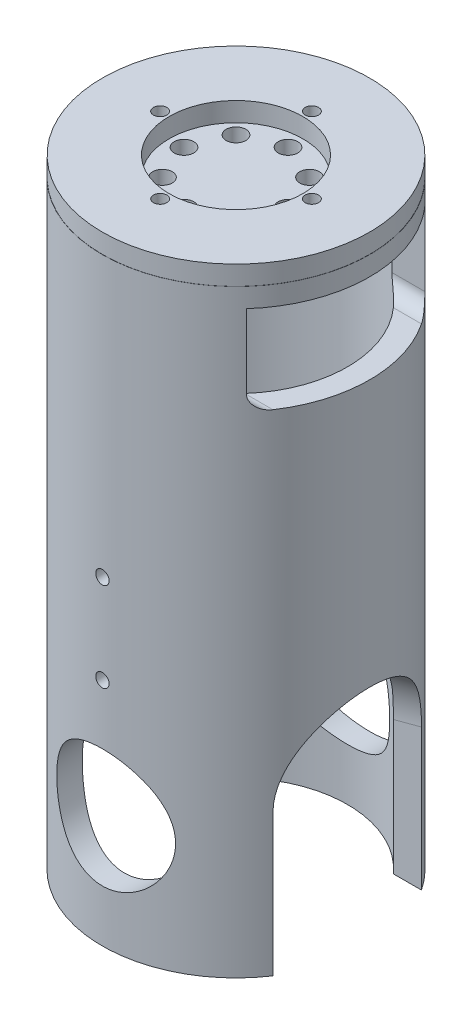
from build123d import *

# Parameters (mm, degrees)
SKETCH1_R                     = 45
BOSS_EXTRUDE2_DEPTH           = 6.5
SKETCH4_R                     = 44.947358216
SKETCH4_R_2                   = 22.5
BOSS_EXTRUDE4_DEPTH           = 6.5
M6_CLEARANCE_HOLE1_D          = 6.6
M6_CLEARANCE_HOLE1_DEPTH      = 10
M6_CLEARANCE_HOLE1_TIP        = 1.982840043
M4_CLEARANCE_HOLE1_D          = 4.5
M4_CLEARANCE_HOLE1_DEPTH      = 20
M4_CLEARANCE_HOLE1_TIP        = 1.351936393
SKETCH18_R                    = 45
SKETCH18_R_2                  = 37.5
BOSS_EXTRUDE7_DEPTH           = 195
SKETCH19_R                    = 20
CUT_EXTRUDE1_DEPTH            = 51
CUT_EXTRUDE1_DEPTH_BACK       = 46
SKETCH21_R                    = 25
CUT_EXTRUDE3_DEPTH            = 65
SKETCH22_R                    = 25
CUT_EXTRUDE4_DEPTH            = 65
CUT_EXTRUDE5_DEPTH            = 47
CUT_EXTRUDE5_DEPTH_BACK       = 47
M4_CLEARANCE_HOLE2_AT_2_COUNT = 2
M4_CLEARANCE_HOLE2_AT_2_PITCH = 30


with BuildPart() as part:
    # Sketch1 → Boss-Extrude2 (new body)
    with BuildSketch(Plane(origin=(0, 0, 0), x_dir=(1, 0, 0), z_dir=(0, 1, 0))):
        Circle(SKETCH1_R)
    extrude(amount=BOSS_EXTRUDE2_DEPTH)

    # Sketch4 → Boss-Extrude4 (add)
    with BuildSketch(Plane(origin=(0, 6.5, 0), x_dir=(1, 0, 0), z_dir=(0, 1, 0))):
        Circle(SKETCH4_R)
        Circle(SKETCH4_R_2, mode=Mode.SUBTRACT)
    extrude(amount=BOSS_EXTRUDE4_DEPTH)

    # M6 Clearance Hole1
    with Locations(Plane(origin=(0, 6.5, 0), x_dir=(1, 0, 0), z_dir=(0, 1, 0))):
        with Locations((0, -17.5), (12.374368671, -12.374368671), (17.5, 0), (12.374368671, 12.374368671), (0, 17.5), (-12.374368671, 12.374368671), (-17.5, 0), (-12.374368671, -12.374368671)):
            Hole(M6_CLEARANCE_HOLE1_D / 2, depth=M6_CLEARANCE_HOLE1_DEPTH)
            with Locations((0, 0, -(M6_CLEARANCE_HOLE1_DEPTH + M6_CLEARANCE_HOLE1_TIP / 2))):  # 118° drill point
                Cone(0, M6_CLEARANCE_HOLE1_D / 2, M6_CLEARANCE_HOLE1_TIP, mode=Mode.SUBTRACT)

    # M4 Clearance Hole1
    with Locations(Plane(origin=(0, 13, 0), x_dir=(1, 0, 0), z_dir=(0, 1, 0))):
        with Locations((0, -25.525), (25.525, 0), (0, 25.525), (-25.525, 0)):
            Hole(M4_CLEARANCE_HOLE1_D / 2, depth=M4_CLEARANCE_HOLE1_DEPTH)
            with Locations((0, 0, -(M4_CLEARANCE_HOLE1_DEPTH + M4_CLEARANCE_HOLE1_TIP / 2))):  # 118° drill point
                Cone(0, M4_CLEARANCE_HOLE1_D / 2, M4_CLEARANCE_HOLE1_TIP, mode=Mode.SUBTRACT)

    # Sketch18 → Boss-Extrude7 (add)
    with BuildSketch(Plane(origin=(0, 0, 0), x_dir=(-1, 0, 0), z_dir=(0, -1, 0))):
        Circle(SKETCH18_R)
        Circle(SKETCH18_R_2, mode=Mode.SUBTRACT)
    extrude(amount=BOSS_EXTRUDE7_DEPTH)

    # Sketch19 → Cut-Extrude1 (cut, two sides)
    with BuildSketch(Plane.XY) as cut_extrude1_sk:
        with Locations((0, -157.5)):
            Circle(SKETCH19_R)
    extrude(amount=CUT_EXTRUDE1_DEPTH, mode=Mode.SUBTRACT)
    extrude(cut_extrude1_sk.sketch, amount=-CUT_EXTRUDE1_DEPTH_BACK, mode=Mode.SUBTRACT)

    # Sketch21 → Cut-Extrude3 (cut)
    with BuildSketch(Plane(origin=(-58.719202908, -141.766237001, 0), x_dir=(0, 0, 1), z_dir=(-0.965925826, 0.258819045, 0))):
        with BuildLine():
            ThreePointArc((25, 0), (0, -25), (-25, 0))
            Line((-25, 0), (-25, -60.548786214))
            Line((-25, -60.548786214), (25, -60.548786214))
            Line((25, -60.548786214), (25, 0))
        make_face()
        Circle(SKETCH21_R)
    extrude(amount=-CUT_EXTRUDE3_DEPTH, mode=Mode.SUBTRACT)

    # Sketch22 → Cut-Extrude4 (cut)
    with BuildSketch(Plane(origin=(54.338492211, -142.940044894, 0), x_dir=(0, 0, -1), z_dir=(0.965925826, 0.258819045, 0))):
        with BuildLine():
            ThreePointArc((25, 0), (0, -25), (-25, 0))
            Line((-25, 0), (-25, -58.09429392))
            Line((-25, -58.09429392), (25, -58.09429392))
            Line((25, -58.09429392), (25, 0))
        make_face()
        Circle(SKETCH22_R)
    extrude(amount=-CUT_EXTRUDE4_DEPTH, mode=Mode.SUBTRACT)

    # Sketch23 → Cut-Extrude5 (cut, two sides)
    with BuildSketch(Plane(origin=(0, 0, 0), x_dir=(0, 0, -1), z_dir=(1, 0, 0))) as cut_extrude5_sk:
        with BuildLine():
            Line((-30, 0), (30, 0))
            Line((30, 0), (30, -25))
            ThreePointArc((30, -25), (28.535533906, -28.535533906), (25, -30))
            Line((25, -30), (-25, -30))
            ThreePointArc((-25, -30), (-28.535533906, -28.535533906), (-30, -25))
            Line((-30, -25), (-30, 0))
        make_face()
    extrude(amount=CUT_EXTRUDE5_DEPTH, mode=Mode.SUBTRACT)
    extrude(cut_extrude5_sk.sketch, amount=-CUT_EXTRUDE5_DEPTH_BACK, mode=Mode.SUBTRACT)

    # Sketch26 → M4 Clearance Hole2 (revolve, cut)
    with BuildSketch(Plane(origin=(0, -117.5, 0), x_dir=(0, 1, 0), z_dir=(1, 0, 0))):
        Polygon((0, 0), (0, 51.351936393), (2.25, 50), (2.25, 0), align=None)
    m4_clearance_hole2 = revolve(axis=Axis((0, -117.5, -6.35), (0, 0, 1)), mode=Mode.SUBTRACT)

    # M4 Clearance Hole2 at 2: M4 Clearance Hole2 ×2
    with Locations(*[(0, i * M4_CLEARANCE_HOLE2_AT_2_PITCH, 0) for i in range(1, M4_CLEARANCE_HOLE2_AT_2_COUNT)]):
        add(m4_clearance_hole2, mode=Mode.SUBTRACT)


solid = part.part
